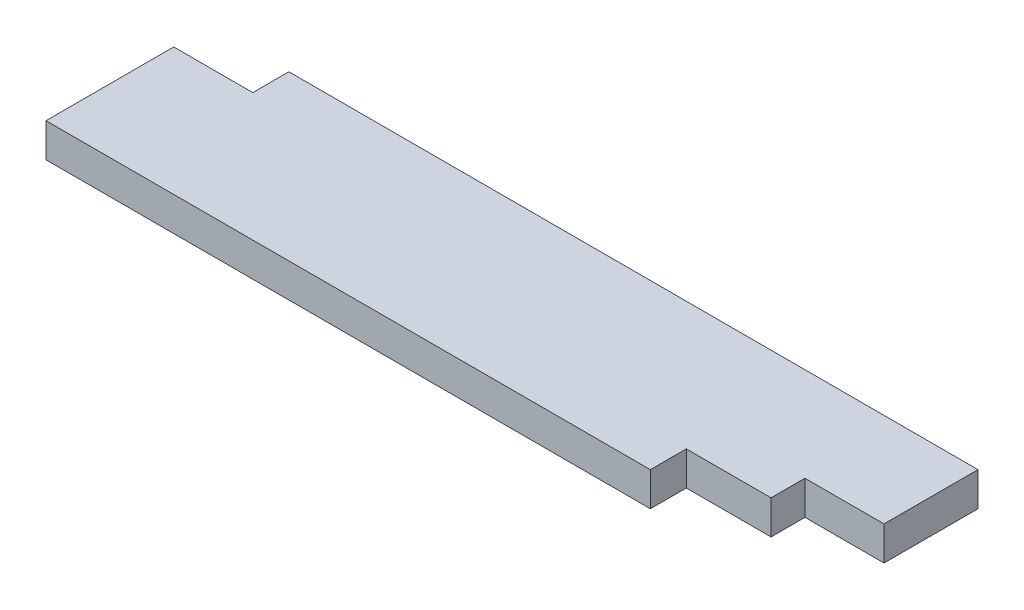
from build123d import *

# Parameters (mm, degrees)
SKETCH1_W           = 863.6
SKETCH1_H           = 184.15
BOSS_EXTRUDE1_DEPTH = 38.1
SKETCH3_W           = 88.9
SKETCH3_H           = 40.5765
CUT_EXTRUDE1_DEPTH  = 39.1


with BuildPart() as part:
    # Sketch1 → Boss-Extrude1 (new body)
    with BuildSketch(Plane(origin=(0, 0, 0), x_dir=(1, 0, 0), z_dir=(0, 1, 0))):
        with Locations((431.8, 92.075)):
            Rectangle(SKETCH1_W, SKETCH1_H)
    extrude(amount=BOSS_EXTRUDE1_DEPTH)

    # Sketch3 → Cut-Extrude1 (cut, through all)
    with BuildSketch(Plane(origin=(0, 38.1, 0), x_dir=(1, 0, 0), z_dir=(0, 1, 0))):
        with Locations((44.45, 163.86175)):
            Rectangle(SKETCH3_W, SKETCH3_H)
        Polygon((863.6, 78.486), (774.7, 78.486), (774.7, 40.386), (679.45, 40.386), (679.45, 0), (863.6, 0), align=None)
    extrude(amount=-CUT_EXTRUDE1_DEPTH, mode=Mode.SUBTRACT)


solid = part.part
